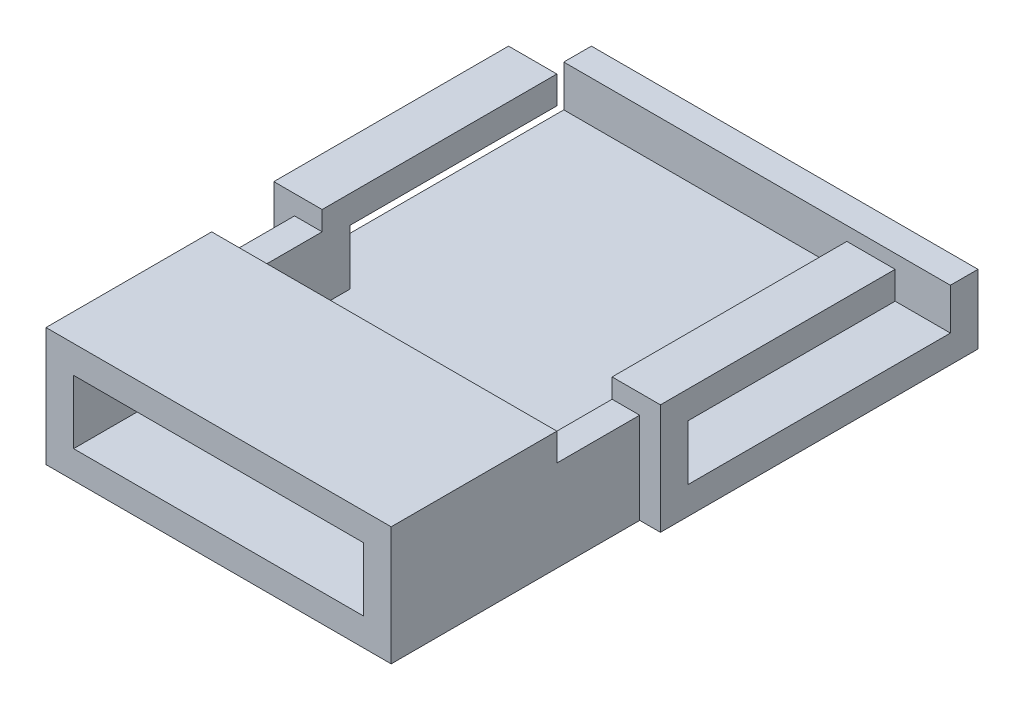
from build123d import *

# Parameters (mm, degrees)
SKETCH_2_W           = 12
SKETCH_2_H           = 9.5
SKETCH_2_W_2         = 10.5
SKETCH_2_H_2         = 9
EXTRUDE_1_DEPTH      = 1
EXTRUDE_2_DEPTH      = 2.3
EXTRUDE_2_DEPTH_BACK = 1
SKETCH_4_W           = 1
SKETCH_4_H           = 9.5
SKETCH_4_W_2         = 10.5
SKETCH_4_H_2         = 1
CUT_EXTRUDE_1_DEPTH  = 2.3
SKETCH_5_W           = 12.5
SKETCH_5_H           = 6
EXTRUDE_3_DEPTH      = 1
SKETCH_6_W           = 1.75
SKETCH_6_H           = 1
CUT_EXTRUDE_3_DEPTH  = 0.3
SKETCH_9_W           = 14
SKETCH_9_H           = 1
CUT_EXTRUDE_4_DEPTH  = 0.8
SKETCH_10_W          = 1.75
SKETCH_10_H          = 7.5
SKETCH_10_H_2        = 8.5
EXTRUDE_7_DEPTH      = 1


with BuildPart() as part:
    # 草图2 → 凸台-拉伸1 (new body)
    with BuildSketch(Plane(origin=(0, 0, 0), x_dir=(1, 0, 0), z_dir=(0, 1, 0))):
        with Locations((0, 4.75)):
            Rectangle(SKETCH_2_W, SKETCH_2_H)
        with Locations((0, -4.5)):
            Rectangle(SKETCH_2_W_2, SKETCH_2_H_2)
    extrude(amount=EXTRUDE_1_DEPTH)

    # 草图3 → 凸台-拉伸2 (add, two sides)
    with BuildSketch(Plane(origin=(0, 1, 0), x_dir=(1, 0, 0), z_dir=(0, 1, 0))) as extrude_2_sk:
        Polygon((7, -1), (7, 10.5), (-7, 10.5), (-7, -1), (-6.25, -1), (-6.25, -10), (6.25, -10), (6.25, -1), align=None)
        Polygon((6, 0), (6, 9.5), (-6, 9.5), (-6, 0), (-5.25, 0), (-5.25, -9), (5.25, -9), (5.25, 0), align=None, mode=Mode.SUBTRACT)
    extrude(amount=EXTRUDE_2_DEPTH)
    extrude(extrude_2_sk.sketch, amount=-EXTRUDE_2_DEPTH_BACK)

    # 草图4 → 切除-拉伸1 (cut)
    with BuildSketch(Plane(origin=(0, 3.3, 0), x_dir=(1, 0, 0), z_dir=(0, 1, 0))):
        with Locations((-6.5, 4.75)):
            Rectangle(SKETCH_4_W, SKETCH_4_H)
        with Locations((6.5, 4.75)):
            Rectangle(SKETCH_4_W, SKETCH_4_H)
        with Locations((0, -9.5)):
            Rectangle(SKETCH_4_W_2, SKETCH_4_H_2)
    extrude(amount=-CUT_EXTRUDE_1_DEPTH, mode=Mode.SUBTRACT)

    # 草图5 → 凸台-拉伸3 (add)
    with BuildSketch(Plane(origin=(0, 3.3, 0), x_dir=(1, 0, 0), z_dir=(0, 1, 0))):
        with Locations((0, -7)):
            Rectangle(SKETCH_5_W, SKETCH_5_H)
    extrude(amount=EXTRUDE_3_DEPTH)

    # 草图6 → 切除-拉伸3 (cut)
    with BuildSketch(Plane(origin=(0, 3.3, 0), x_dir=(1, 0, 0), z_dir=(0, 1, 0))):
        with Locations((-6.125, -0.5)):
            Rectangle(SKETCH_6_W, SKETCH_6_H)
        with Locations((6.125, -0.5)):
            Rectangle(SKETCH_6_W, SKETCH_6_H)
    extrude(amount=-CUT_EXTRUDE_3_DEPTH, mode=Mode.SUBTRACT)

    # 草图9 → 切除-拉伸4 (cut)
    with BuildSketch(Plane(origin=(0, 3.3, 0), x_dir=(1, 0, 0), z_dir=(0, 1, 0))):
        with Locations((0, 10)):
            Rectangle(SKETCH_9_W, SKETCH_9_H)
    extrude(amount=-CUT_EXTRUDE_4_DEPTH, mode=Mode.SUBTRACT)

    # 草图10 → 凸台-拉伸7 (add)
    with BuildSketch(Plane(origin=(0, 3, 0), x_dir=(1, 0, 0), z_dir=(0, 1, 0))):
        with Locations((-6.125, 3.75)):
            Rectangle(SKETCH_10_W, SKETCH_10_H)
        with Locations((6.125, 3.25)):
            Rectangle(SKETCH_10_W, SKETCH_10_H_2)
        Polygon((-5.25, 0), (-7, 0), (-7, -1), (-6.25, -1), (-5.25, -1), align=None)
    extrude(amount=EXTRUDE_7_DEPTH)


solid = part.part
